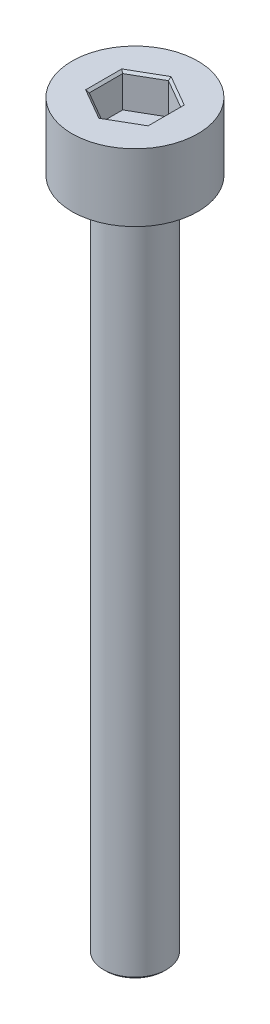
from build123d import *

# Parameters (mm, degrees)
SKETCH_1_R          = 2.8
EXTRUDE_1_DEPTH     = 3
CUT_EXTRUDE_1_DEPTH = 1.5
SKETCH_3_R          = 1.4
EXTRUDE_2_DEPTH     = 30
CHAMFER_1_SIZE      = 0.1


with BuildPart() as part:
    # 草图1 → 凸台-拉伸1 (new body)
    with BuildSketch(Plane(origin=(0, 0, 0), x_dir=(1, 0, 0), z_dir=(0, 1, 0))):
        Circle(SKETCH_1_R)
    extrude(amount=EXTRUDE_1_DEPTH)

    # 草图2 → 切除-拉伸1 (cut)
    with BuildSketch(Plane(origin=(0, 3, 0), x_dir=(1, 0, 0), z_dir=(0, 1, 0))):
        Polygon((0, -1.489563695), (1.29, -0.744781847), (1.29, 0.744781847), (0, 1.489563695), (-1.29, 0.744781847), (-1.29, -0.744781847), align=None)
    extrude(amount=-CUT_EXTRUDE_1_DEPTH, mode=Mode.SUBTRACT)

    # 草图3 → 凸台-拉伸2 (add)
    with BuildSketch(Plane.XZ):
        Circle(SKETCH_3_R)
    extrude(amount=EXTRUDE_2_DEPTH)

    # 倒角1
    chamfer_1_edges = [part.edges().sort_by_distance(p)[0] for p in [
        (-0.645, 3, 1.117172771),
        (0.645, 3, 1.117172771),
        (1.29, 3, 0),
        (0.645, 3, -1.117172771),
        (-0.645, 3, -1.117172771),
        (-1.29, 3, 0),
        (-1.4, -30, 0),
    ]]
    chamfer(chamfer_1_edges, length=CHAMFER_1_SIZE)


solid = part.part
